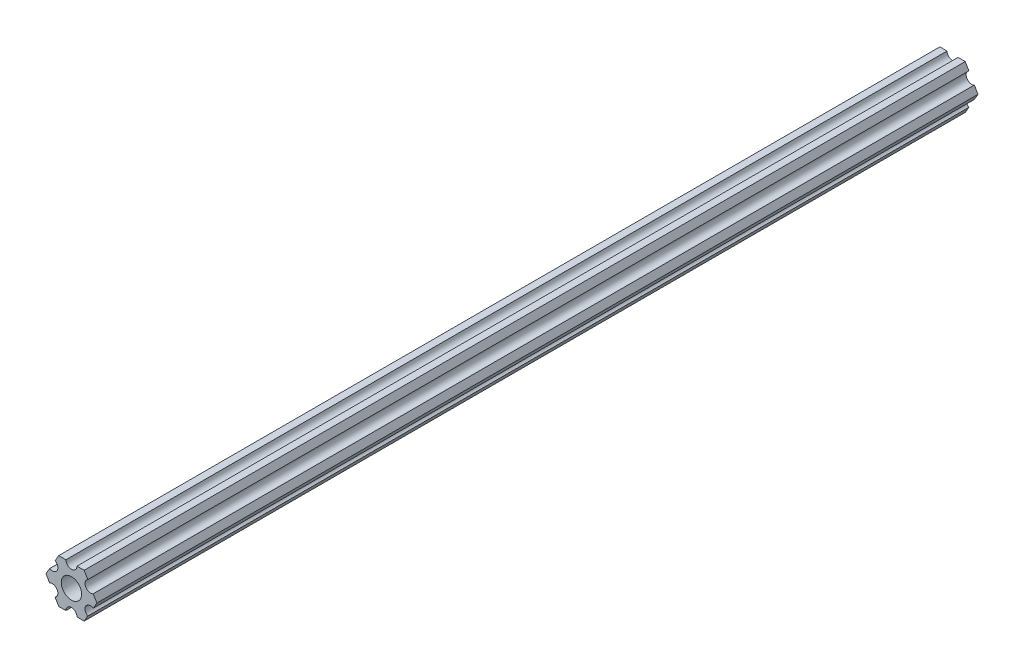
from build123d import *

# Parameters (mm, degrees)
SKETCH1_R           = 2.9337
BOSS_EXTRUDE1_DEPTH = 254


with BuildPart() as part:
    # Sketch1 → Boss-Extrude1 (new body)
    with BuildSketch(Plane.XY):
        with BuildLine():
            Line((-4.70551159, -4.549815043), (-3.666174521, -6.349999904))
            Line((-3.666174521, -6.349999904), (-1.587501154, -6.349999904))
            ThreePointArc((-1.587501154, -6.349999904), (-3.85e-07, -4.762499134), (1.587501154, -6.349999904))
            Line((1.587501154, -6.349999904), (3.666173825, -6.349999904))
            Line((3.666173825, -6.349999904), (4.705510929, -4.549815232))
            ThreePointArc((4.705510929, -4.549815232), (4.124445601, -2.381249904), (6.293010929, -1.800184575))
            Line((6.293010929, -1.800184575), (7.332348034, 9.6e-08))
            Line((7.332348034, 9.6e-08), (6.293011178, 1.800184715))
            ThreePointArc((6.293011178, 1.800184715), (4.124445902, 2.381250241), (4.705511428, 4.549815516))
            Line((4.705511428, 4.549815516), (3.666174521, 6.350000222))
            Line((3.666174521, 6.350000222), (1.587498846, 6.350000222))
            ThreePointArc((1.587498846, 6.350000222), (3.85e-07, 4.762501761), (-1.587498846, 6.350000222))
            Line((-1.587498846, 6.350000222), (-3.666173825, 6.350000222))
            Line((-3.666173825, 6.350000222), (-4.705511038, 4.549815614))
            ThreePointArc((-4.705511038, 4.549815614), (-4.124445841, 2.38125025), (-6.293011205, 1.800185053))
            Line((-6.293011205, 1.800185053), (-7.332348419, 4.44e-07))
            Line((-7.332348419, 4.44e-07), (-6.293011423, -1.80018429))
            ThreePointArc((-6.293011423, -1.80018429), (-4.12444613, -2.38124975), (-4.70551159, -4.549815043))
        make_face()
        Circle(SKETCH1_R, mode=Mode.SUBTRACT)
    extrude(amount=-BOSS_EXTRUDE1_DEPTH)


solid = part.part
